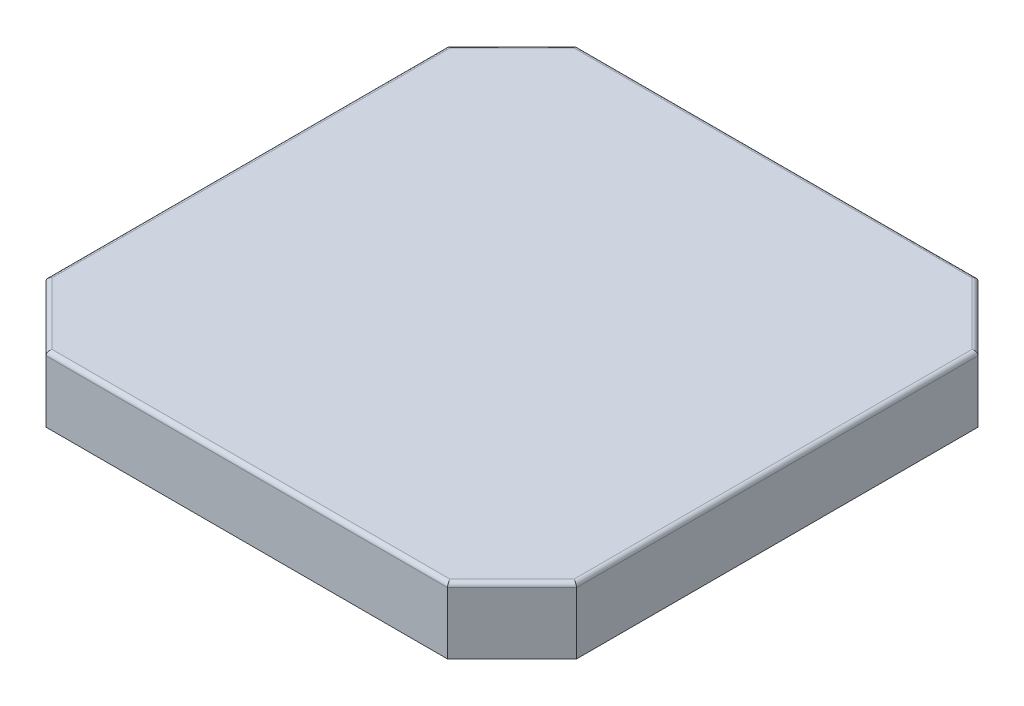
from build123d import *

# Parameters (mm, degrees)
ESQUISSE1_W             = 24.7
ESQUISSE1_H             = 24.7
BOSS_EXTRU_1_DEPTH      = 3.08
CHANFREIN1_SIZE         = 3
CONG_1_R                = 0.2
ESQUISSE2_W             = 6
ESQUISSE2_H             = 2.88
ENL_V_MAT_EXTRU_1_DEPTH = 22.08
ENL_V_MAT_EXTRU_2_DEPTH = 2.88
SKETCH1_R               = 0.5
BOSS_EXTRUDE1_DEPTH     = 0.5
BOSS_EXTRUDE1_2_DEPTH   = 0.5


with BuildPart() as part:
    # Esquisse1 → Boss.-Extru.1 (new body)
    with BuildSketch(Plane(origin=(0, 0, 0), x_dir=(1, 0, 0), z_dir=(0, 1, 0))):
        with Locations((12.35, 12.35)):
            Rectangle(ESQUISSE1_W, ESQUISSE1_H)
    extrude(amount=BOSS_EXTRU_1_DEPTH)

    # Chanfrein1
    chanfrein1_edges = [part.edges().sort_by_distance(p)[0] for p in [
        (0, 1.54, -24.7),
        (24.7, 1.54, -24.7),
        (24.7, 1.54, 0),
        (0, 1.54, 0),
    ]]
    chamfer(chanfrein1_edges, length=CHANFREIN1_SIZE)

    # Congé1
    cong_1_edges = [part.edges().sort_by_distance(p)[0] for p in [
        (0, 3.08, -12.35),
        (12.35, 3.08, -24.7),
        (12.35, 3.08, 0),
        (24.7, 3.08, -12.35),
        (1.5, 3.08, -1.5),
        (23.2, 3.08, -1.5),
        (23.2, 3.08, -23.2),
        (1.5, 3.08, -23.2),
    ]]
    fillet(cong_1_edges, radius=CONG_1_R)

    # Esquisse2 → Enlèv. mat.-Extru.1 (cut)
    with BuildSketch(Plane(origin=(0, 0, -24.7), x_dir=(-1, 0, 0), z_dir=(0, 0, -1))):
        with Locations((-12.35, 1.44)):
            Rectangle(ESQUISSE2_W, ESQUISSE2_H)
    extrude(amount=-ENL_V_MAT_EXTRU_1_DEPTH, mode=Mode.SUBTRACT)

    # Esquisse3 → Enlèv. mat.-Extru.2 (cut)
    with BuildSketch(Plane.XZ):
        Polygon((3.124264069, -24.4), (21.575735931, -24.4), (24.4, -21.575735931), (24.4, -3.124264069), (21.575735931, -0.3), (3.124264069, -0.3), (0.3, -3.124264069), (0.3, -21.575735931), align=None)
    extrude(amount=-ENL_V_MAT_EXTRU_2_DEPTH, mode=Mode.SUBTRACT)


with BuildPart() as body_2:
    # Sketch1 → Boss-Extrude1 (new body)
    with BuildSketch(Plane(origin=(0, 0, -24.7), x_dir=(-1, 0, 0), z_dir=(0, 0, -1))):
        with Locations((-11.42912296, 1.472678578)):
            Circle(SKETCH1_R)
    extrude(amount=BOSS_EXTRUDE1_DEPTH)


with BuildPart() as body_3:
    # Sketch1 → Boss-Extrude1 2 (new body)
    with BuildSketch(Plane(origin=(0, 0, -24.7), x_dir=(-1, 0, 0), z_dir=(0, 0, -1))):
        with Locations((-13.030297456, 1.442750083)):
            Circle(SKETCH1_R)
    extrude(amount=BOSS_EXTRUDE1_2_DEPTH)


solid = Compound([part.part, body_2.part, body_3.part])
